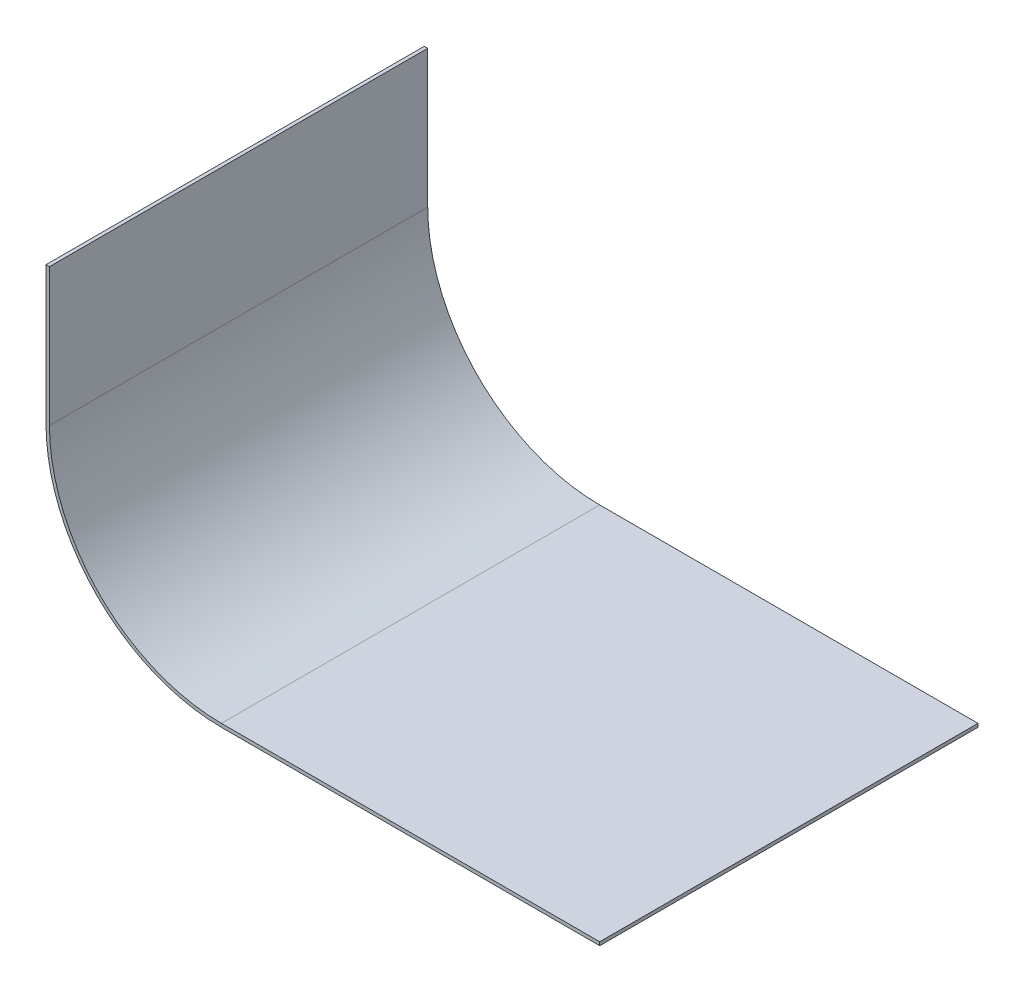
from build123d import *

# Parameters (mm, degrees)
BOSS_EXTRUDE1_DEPTH = 11


with BuildPart() as part:
    # Sketch1 → Boss-Extrude1 (new body)
    with BuildSketch(Plane.XY):
        with BuildLine():
            Line((0, 0), (0, -4))
            ThreePointArc((0, -4), (1.464466094, -7.535533906), (5, -9))
            Line((5, -9), (16, -9))
            Line((16, -9), (16, -9.1))
            Line((16, -9.1), (5, -9.1))
            ThreePointArc((5, -9.1), (1.393755416, -7.606244584), (-0.1, -4))
            Line((-0.1, -4), (-0.1, 0))
            Line((-0.1, 0), (0, 0))
        make_face()
    extrude(amount=BOSS_EXTRUDE1_DEPTH)


solid = part.part
